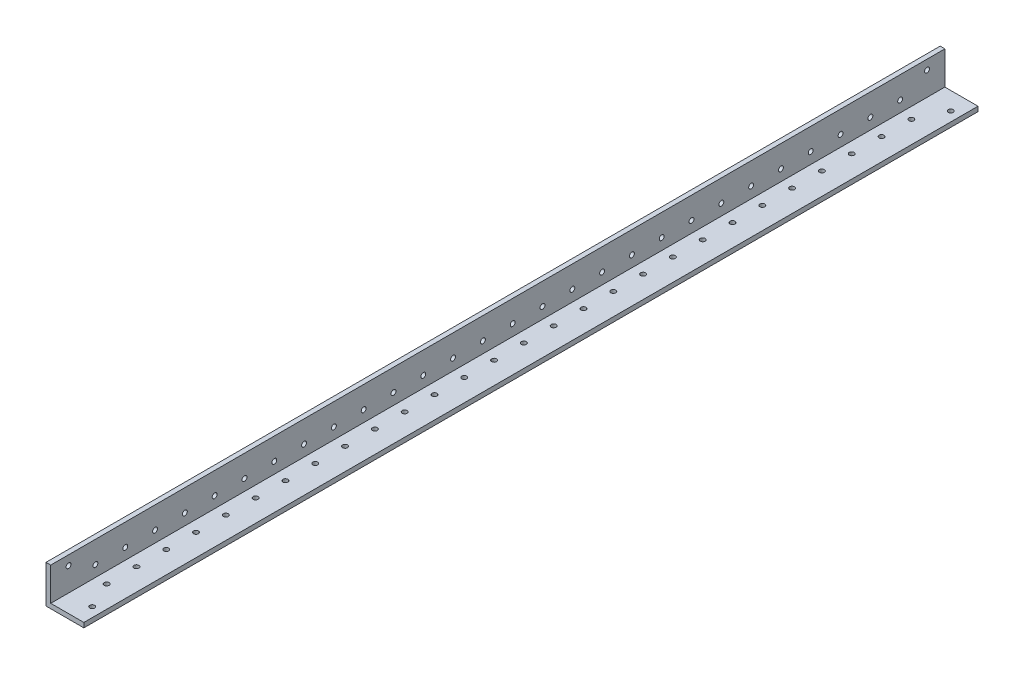
from build123d import *

# Parameters (mm, degrees)
BOSS_EXTRUDE1_DEPTH = 1219.2
FILLET1_R           = 0.4064
SKETCH4_W           = 1838.4
SKETCH4_H           = 103.278519729
CUT_EXTRUDE1_DEPTH  = 60
SKETCH5_W           = 2.838427027
SKETCH5_H           = 1.970979722
CUT_EXTRUDE2_DEPTH  = 700
SKETCH9_R           = 1.65
CUT_EXTRUDE5_DEPTH  = 20
SKETCH10_R          = 1.65
CUT_EXTRUDE6_DEPTH  = 20
SKETCH11_R          = 1.65
CUT_EXTRUDE7_DEPTH  = 70
SKETCH12_R          = 1.65
CUT_EXTRUDE8_DEPTH  = 70


with BuildPart() as part:
    # Sketch3 → Boss-Extrude1 (new, symmetric)
    with BuildSketch(Plane.XY):
        Polygon((3.175, 25.4), (0, 25.4), (0, 0), (25.4, 0), (25.4, 3.175), (3.175, 3.175), align=None)
    extrude(amount=BOSS_EXTRUDE1_DEPTH, both=True)

    # Fillet1
    fillet1_edges = [part.edges().sort_by_distance(p)[0] for p in [
        (3.175, 3.175, 0),
    ]]
    fillet(fillet1_edges, radius=FILLET1_R)

    # Sketch4 → Cut-Extrude1 (cut)
    with BuildSketch(Plane.ZY):
        with Locations((-300, -26.239259864)):
            Rectangle(SKETCH4_W, SKETCH4_H)
    extrude(amount=-CUT_EXTRUDE1_DEPTH, mode=Mode.SUBTRACT)

    # Sketch5 → Cut-Extrude2 (cut)
    with BuildSketch(Plane(origin=(0, 0, 619.2), x_dir=(-1, 0, 0), z_dir=(0, 0, -1))):
        with Locations((-4.594213514, 4.160489861)):
            Rectangle(SKETCH5_W, SKETCH5_H)
    extrude(amount=-CUT_EXTRUDE2_DEPTH, mode=Mode.SUBTRACT)

    # Sketch9 → Cut-Extrude5 (cut)
    with BuildSketch(Plane(origin=(3.175, 0, 0), x_dir=(0, 0, -1), z_dir=(1, 0, 0))):
        with Locations(Location((-649.2, 10.675, 0), (0, 0, 90))):
            Circle(SKETCH9_R)
        with Locations(Location((-669.2, 10.675, 0), (0, 0, 90))):
            Circle(SKETCH9_R)
        with Locations(Location((-689.2, 10.675, 0), (0, 0, 90))):
            Circle(SKETCH9_R)
        with Locations(Location((-709.2, 10.675, 0), (0, 0, 90))):
            Circle(SKETCH9_R)
        with Locations(Location((-729.2, 10.675, 0), (0, 0, 90))):
            Circle(SKETCH9_R)
        with Locations(Location((-749.2, 10.675, 0), (0, 0, 90))):
            Circle(SKETCH9_R)
        with Locations(Location((-769.2, 10.675, 0), (0, 0, 90))):
            Circle(SKETCH9_R)
        with Locations(Location((-789.2, 10.675, 0), (0, 0, 90))):
            Circle(SKETCH9_R)
        with Locations(Location((-809.2, 10.675, 0), (0, 0, 90))):
            Circle(SKETCH9_R)
        with Locations(Location((-829.2, 10.675, 0), (0, 0, 90))):
            Circle(SKETCH9_R)
        with Locations(Location((-849.2, 10.675, 0), (0, 0, 90))):
            Circle(SKETCH9_R)
        with Locations(Location((-869.2, 10.675, 0), (0, 0, 90))):
            Circle(SKETCH9_R)
        with Locations(Location((-889.2, 10.675, 0), (0, 0, 90))):
            Circle(SKETCH9_R)
        with Locations(Location((-909.2, 10.675, 0), (0, 0, 90))):
            Circle(SKETCH9_R)
        with Locations(Location((-929.2, 10.675, 0), (0, 0, 90))):
            Circle(SKETCH9_R)
        with Locations(Location((-949.2, 10.675, 0), (0, 0, 90))):
            Circle(SKETCH9_R)
        with Locations(Location((-969.2, 10.675, 0), (0, 0, 90))):
            Circle(SKETCH9_R)
        with Locations(Location((-989.2, 10.675, 0), (0, 0, 90))):
            Circle(SKETCH9_R)
        with Locations(Location((-1009.2, 10.675, 0), (0, 0, 90))):
            Circle(SKETCH9_R)
        with Locations(Location((-1029.2, 10.675, 0), (0, 0, 90))):
            Circle(SKETCH9_R)
        with Locations(Location((-1049.2, 10.675, 0), (0, 0, 90))):
            Circle(SKETCH9_R)
        with Locations(Location((-1069.2, 10.675, 0), (0, 0, 90))):
            Circle(SKETCH9_R)
        with Locations(Location((-1089.2, 10.675, 0), (0, 0, 90))):
            Circle(SKETCH9_R)
        with Locations(Location((-1109.2, 10.675, 0), (0, 0, 90))):
            Circle(SKETCH9_R)
        with Locations(Location((-1129.2, 10.675, 0), (0, 0, 90))):
            Circle(SKETCH9_R)
        with Locations(Location((-1149.2, 10.675, 0), (0, 0, 90))):
            Circle(SKETCH9_R)
        with Locations(Location((-1169.2, 10.675, 0), (0, 0, 90))):
            Circle(SKETCH9_R)
        with Locations(Location((-1189.2, 10.675, 0), (0, 0, 90))):
            Circle(SKETCH9_R)
    extrude(amount=-CUT_EXTRUDE5_DEPTH, mode=Mode.SUBTRACT)

    # Sketch10 → Cut-Extrude6 (cut)
    with BuildSketch(Plane(origin=(0, 3.175, 0), x_dir=(1, 0, 0), z_dir=(0, 1, 0))):
        with Locations(Location((10.675, -649.2, 0), (0, 0, 180))):
            Circle(SKETCH10_R)
        with Locations(Location((10.675, -669.2, 0), (0, 0, 180))):
            Circle(SKETCH10_R)
        with Locations(Location((10.675, -689.2, 0), (0, 0, 180))):
            Circle(SKETCH10_R)
        with Locations(Location((10.675, -709.2, 0), (0, 0, 180))):
            Circle(SKETCH10_R)
        with Locations(Location((10.675, -729.2, 0), (0, 0, 180))):
            Circle(SKETCH10_R)
        with Locations(Location((10.675, -749.2, 0), (0, 0, 180))):
            Circle(SKETCH10_R)
        with Locations(Location((10.675, -769.2, 0), (0, 0, 180))):
            Circle(SKETCH10_R)
        with Locations(Location((10.675, -789.2, 0), (0, 0, 180))):
            Circle(SKETCH10_R)
        with Locations(Location((10.675, -809.2, 0), (0, 0, 180))):
            Circle(SKETCH10_R)
        with Locations(Location((10.675, -829.2, 0), (0, 0, 180))):
            Circle(SKETCH10_R)
        with Locations(Location((10.675, -849.2, 0), (0, 0, 180))):
            Circle(SKETCH10_R)
        with Locations(Location((10.675, -869.2, 0), (0, 0, 180))):
            Circle(SKETCH10_R)
        with Locations(Location((10.675, -889.2, 0), (0, 0, 180))):
            Circle(SKETCH10_R)
        with Locations(Location((10.675, -909.2, 0), (0, 0, 180))):
            Circle(SKETCH10_R)
        with Locations(Location((10.675, -929.2, 0), (0, 0, 180))):
            Circle(SKETCH10_R)
        with Locations(Location((10.675, -949.2, 0), (0, 0, 180))):
            Circle(SKETCH10_R)
        with Locations(Location((10.675, -969.2, 0), (0, 0, 180))):
            Circle(SKETCH10_R)
        with Locations(Location((10.675, -989.2, 0), (0, 0, 180))):
            Circle(SKETCH10_R)
        with Locations(Location((10.675, -1009.2, 0), (0, 0, 180))):
            Circle(SKETCH10_R)
        with Locations(Location((10.675, -1029.2, 0), (0, 0, 180))):
            Circle(SKETCH10_R)
        with Locations(Location((10.675, -1049.2, 0), (0, 0, 180))):
            Circle(SKETCH10_R)
        with Locations(Location((10.675, -1069.2, 0), (0, 0, 180))):
            Circle(SKETCH10_R)
        with Locations(Location((10.675, -1089.2, 0), (0, 0, 180))):
            Circle(SKETCH10_R)
        with Locations(Location((10.675, -1109.2, 0), (0, 0, 180))):
            Circle(SKETCH10_R)
        with Locations(Location((10.675, -1129.2, 0), (0, 0, 180))):
            Circle(SKETCH10_R)
        with Locations(Location((10.675, -1149.2, 0), (0, 0, 180))):
            Circle(SKETCH10_R)
        with Locations(Location((10.675, -1169.2, 0), (0, 0, 180))):
            Circle(SKETCH10_R)
        with Locations(Location((10.675, -1189.2, 0), (0, 0, 180))):
            Circle(SKETCH10_R)
    extrude(amount=-CUT_EXTRUDE6_DEPTH, mode=Mode.SUBTRACT)

    # Sketch11 → Cut-Extrude7 (cut)
    with BuildSketch(Plane(origin=(0, 3.175, 0), x_dir=(1, 0, 0), z_dir=(0, 1, 0))):
        with Locations(Location((19.05, -1207.2366, 0), (0, 0, 180))):
            Circle(SKETCH11_R)
        with Locations(Location((19.05, -631.1634, 0), (0, 0, 180))):
            Circle(SKETCH11_R)
    extrude(amount=-CUT_EXTRUDE7_DEPTH, mode=Mode.SUBTRACT)

    # Sketch12 → Cut-Extrude8 (cut)
    with BuildSketch(Plane(origin=(3.175, 0, 0), x_dir=(0, 0, -1), z_dir=(1, 0, 0))):
        with Locations(Location((-1207.2366, 19.05, 0), (0, 0, 90))):
            Circle(SKETCH12_R)
        with Locations(Location((-631.1634, 19.05, 0), (0, 0, 90))):
            Circle(SKETCH12_R)
    extrude(amount=-CUT_EXTRUDE8_DEPTH, mode=Mode.SUBTRACT)


solid = part.part
